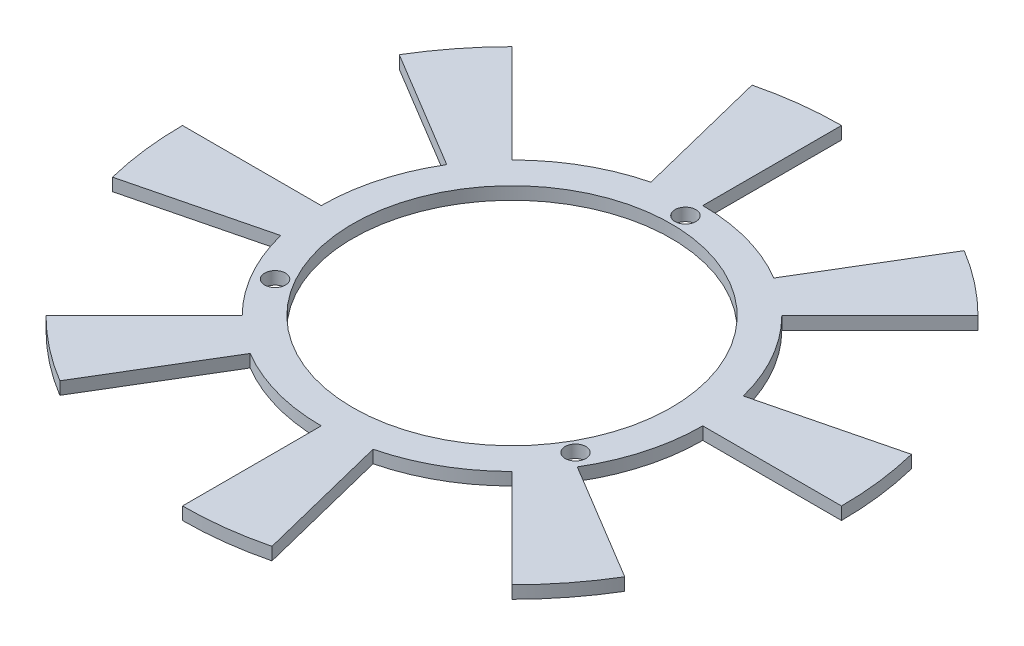
from build123d import *

# Parameters (mm, degrees)
SKETCH1_R           = 30.25
SKETCH1_R_2         = 25.25
EXTRUDE_THIN1_DEPTH = 2
SKETCH2_R           = 1.65
CUT_EXTRUDE3_DEPTH  = 10
BOSS_EXTRUDE1_DEPTH = 2


with BuildPart() as part:
    # Sketch1 → Extrude-Thin1 (new body)
    with BuildSketch(Plane(origin=(0, 0, 0), x_dir=(1, 0, 0), z_dir=(0, 1, 0))):
        Circle(SKETCH1_R)
        Circle(SKETCH1_R_2, mode=Mode.SUBTRACT)
    extrude(amount=-EXTRUDE_THIN1_DEPTH)

    # Sketch2 → Cut-Extrude3 (cut)
    with BuildSketch(Plane(origin=(0, 0, 0), x_dir=(1, 0, 0), z_dir=(0, 1, 0))):
        with Locations((0, 27.5)):
            Circle(SKETCH2_R)
        with Locations((23.815698604, -13.75)):
            Circle(SKETCH2_R)
        with Locations((-23.815698604, -13.75)):
            Circle(SKETCH2_R)
    extrude(amount=-CUT_EXTRUDE3_DEPTH, mode=Mode.SUBTRACT)

    # Sketch5 → Boss-Extrude1 (add)
    with BuildSketch(Plane.XZ.offset(2)):
        with BuildLine():
            Line((0, 52.25), (0, 30.25))
            ThreePointArc((0, 30.25), (3.686547638, 30.024521087), (7.318137342, 29.35144572))
            Line((7.318137342, 29.35144572), (12.640419045, 50.697951698))
            ThreePointArc((12.640419045, 50.697951698), (6.367673193, 51.860536423), (0, 52.25))
        make_face()
        with BuildLine():
            Line((36.946329317, 36.946329317), (21.389980131, 21.389980131))
            ThreePointArc((21.389980131, 21.389980131), (23.837325297, 18.623759629), (25.929310846, 15.579901766))
            Line((25.929310846, 15.579901766), (44.786991462, 26.910739414))
            ThreePointArc((44.786991462, 26.910739414), (41.173561876, 32.168312086), (36.946329317, 36.946329317))
        make_face()
        with BuildLine():
            Line((52.25, 0), (30.25, 0))
            ThreePointArc((30.25, 0), (30.024521087, -3.686547638), (29.35144572, -7.318137342))
            Line((29.35144572, -7.318137342), (50.697951698, -12.640419045))
            ThreePointArc((50.697951698, -12.640419045), (51.860536423, -6.367673193), (52.25, 0))
        make_face()
        with BuildLine():
            Line((36.946329317, -36.946329317), (21.389980131, -21.389980131))
            ThreePointArc((21.389980131, -21.389980131), (18.623759629, -23.837325297), (15.579901766, -25.929310846))
            Line((15.579901766, -25.929310846), (26.910739414, -44.786991462))
            ThreePointArc((26.910739414, -44.786991462), (32.168312086, -41.173561876), (36.946329317, -36.946329317))
        make_face()
        with BuildLine():
            Line((0, -52.25), (0, -30.25))
            ThreePointArc((0, -30.25), (-3.686547638, -30.024521087), (-7.318137342, -29.35144572))
            Line((-7.318137342, -29.35144572), (-12.640419045, -50.697951698))
            ThreePointArc((-12.640419045, -50.697951698), (-6.367673193, -51.860536423), (0, -52.25))
        make_face()
        with BuildLine():
            Line((-36.946329317, -36.946329317), (-21.389980131, -21.389980131))
            ThreePointArc((-21.389980131, -21.389980131), (-23.837325297, -18.623759629), (-25.929310846, -15.579901766))
            Line((-25.929310846, -15.579901766), (-44.786991462, -26.910739414))
            ThreePointArc((-44.786991462, -26.910739414), (-41.173561876, -32.168312086), (-36.946329317, -36.946329317))
        make_face()
        with BuildLine():
            Line((-52.25, 0), (-30.25, 0))
            ThreePointArc((-30.25, 0), (-30.024521087, 3.686547638), (-29.35144572, 7.318137342))
            Line((-29.35144572, 7.318137342), (-50.697951698, 12.640419045))
            ThreePointArc((-50.697951698, 12.640419045), (-51.860536423, 6.367673193), (-52.25, 0))
        make_face()
        with BuildLine():
            Line((-36.946329317, 36.946329317), (-21.389980131, 21.389980131))
            ThreePointArc((-21.389980131, 21.389980131), (-18.623759629, 23.837325297), (-15.579901766, 25.929310846))
            Line((-15.579901766, 25.929310846), (-26.910739414, 44.786991462))
            ThreePointArc((-26.910739414, 44.786991462), (-32.168312086, 41.173561876), (-36.946329317, 36.946329317))
        make_face()
    extrude(amount=-BOSS_EXTRUDE1_DEPTH)


solid = part.part
